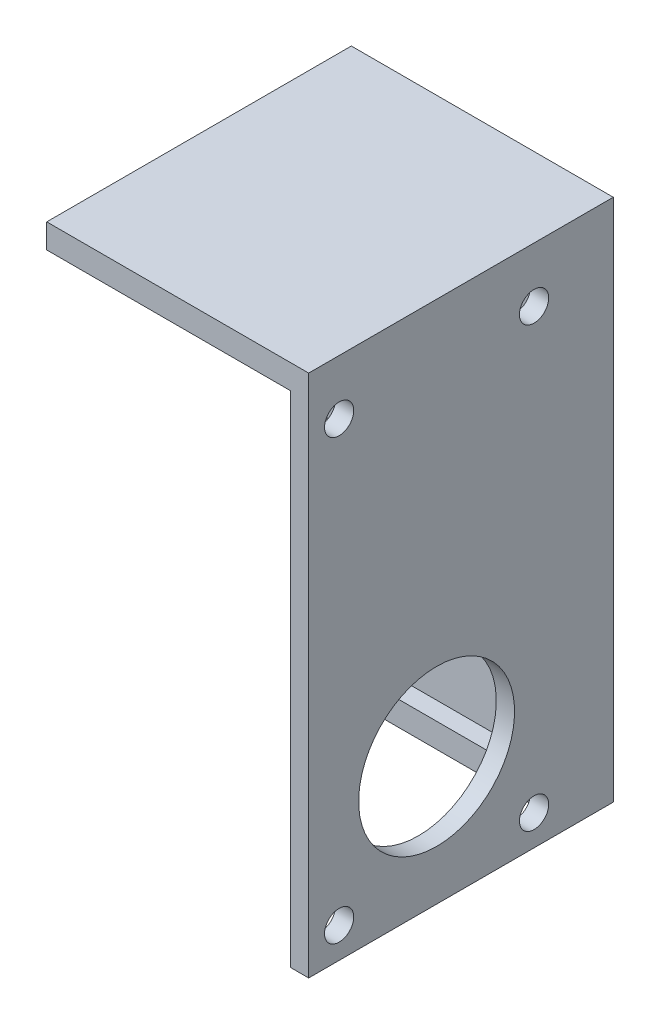
from build123d import *

# Parameters (mm, degrees)
SKETCH_1_W          = 20
SKETCH_1_H          = 41
SKETCH_1_R          = 1.3
EXTRUDE_1_DEPTH     = 2
SKETCH_1_3_W        = 1.5
SKETCH_1_3_H        = 41
EXTRUDE_2_DEPTH     = 25
SKETCH_2_R          = 1.2
SKETCH_2_R_2        = 6.4
CUT_EXTRUDE_1_DEPTH = 39.826537317
EXTRUDE_6_DEPTH     = 25
SKETCH_4_W          = 20
SKETCH_4_H          = 2
EXTRUDE_8_DEPTH     = 1.5


with BuildPart() as part:
    # 草圖1 → 填料-伸長1 (new body)
    with BuildSketch(Plane.XY):
        Rectangle(SKETCH_1_W, SKETCH_1_H)
        with Locations((-4.949747468, -4.949747468)):
            Circle(SKETCH_1_R, mode=Mode.SUBTRACT)
        with Locations((-7, 0)):
            Circle(SKETCH_1_R, mode=Mode.SUBTRACT)
        with Locations((0, -7)):
            Circle(SKETCH_1_R, mode=Mode.SUBTRACT)
        with Locations((4.949747468, -4.949747468)):
            Circle(SKETCH_1_R, mode=Mode.SUBTRACT)
        with Locations((7, 0)):
            Circle(SKETCH_1_R, mode=Mode.SUBTRACT)
        with Locations((-4.949747468, 4.949747468)):
            Circle(SKETCH_1_R, mode=Mode.SUBTRACT)
        with Locations((0, 7)):
            Circle(SKETCH_1_R, mode=Mode.SUBTRACT)
        with Locations((4.949747468, 4.949747468)):
            Circle(SKETCH_1_R, mode=Mode.SUBTRACT)
    extrude(amount=EXTRUDE_1_DEPTH)

    # 草圖1<3> → 填料-伸長2 (add)
    with BuildSketch(Plane.XY):
        with Locations((10.75, 0)):
            Rectangle(SKETCH_1_3_W, SKETCH_1_3_H)
    extrude(amount=EXTRUDE_2_DEPTH)

    # 草圖2 → 除料-伸長1 (cut, through all)
    with BuildSketch(Plane(origin=(11.5, 0, 0), x_dir=(0, 0, -1), z_dir=(1, 0, 0))):
        with Locations((-22.5, -18)):
            Circle(SKETCH_2_R)
        with Locations((-22.5, 18)):
            Circle(SKETCH_2_R)
        with Locations((-6.5, 18)):
            Circle(SKETCH_2_R)
        with Locations((-6.5, -18)):
            Circle(SKETCH_2_R)
        with Locations((-14.5, -10)):
            Circle(SKETCH_2_R_2)
    extrude(amount=-CUT_EXTRUDE_1_DEPTH, mode=Mode.SUBTRACT)

    # 草圖1<6> → 填料-伸長6 (add)
    with BuildSketch(Plane.XY):
        Polygon((-10, 22.5), (-10, 20.5), (10, 20.5), (11.5, 20.5), (11.5, 22.5), align=None)
    extrude(amount=EXTRUDE_6_DEPTH)

    # 草圖4 → 填料-伸長8 (add)
    with BuildSketch(Plane.XY.offset(2)):
        with Locations((0, -19.5)):
            Rectangle(SKETCH_4_W, SKETCH_4_H)
    extrude_8 = extrude(amount=EXTRUDE_8_DEPTH)

    # 鏡射1: 填料-伸長8 across plane
    add(extrude_8.mirror(Plane.ZX))


solid = part.part
